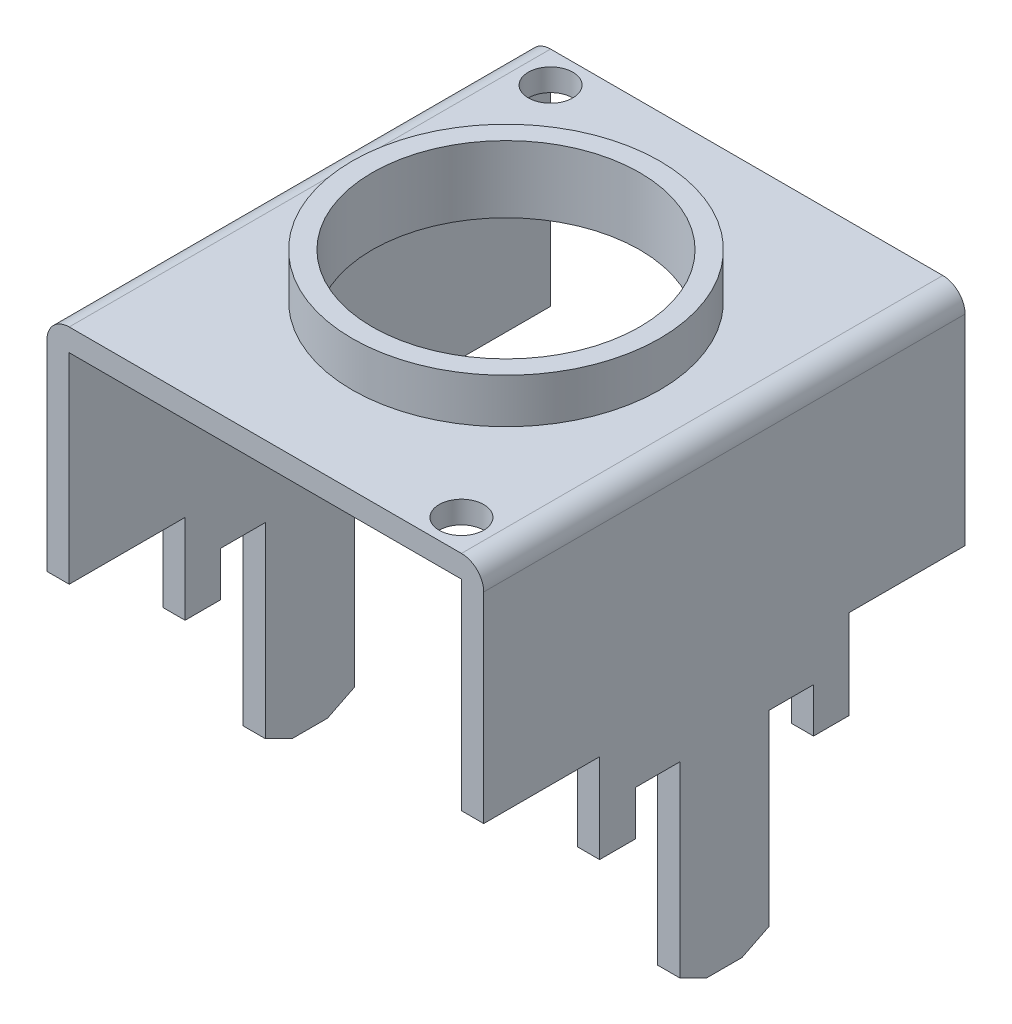
from build123d import *

# Parameters (mm, degrees)
EXTRU_MINCE1_DEPTH           = 5.4
EXTRU_MINCE1_DEPTH_BACK      = 5.4
ENL_V_MAT_EXTRU_1_DEPTH      = 5.9
ENL_V_MAT_EXTRU_1_DEPTH_BACK = 5.9
ESQUISSE4_R                  = 0.5
ENL_V_MAT_EXTRU_2_DEPTH      = 11.5
ESQUISSE5_R                  = 3.45
ESQUISSE5_R_2                = 3
BOSS_EXTRU_1_DEPTH           = 1
ESQUISSE6_R                  = 3
ENL_V_MAT_EXTRU_3_DEPTH      = 11.5


with BuildPart() as part:
    # Esquisse1 → Extru.-Mince1 (new body, two sides)
    with BuildSketch(Plane.XY) as extru_mince1_sk:
        with BuildLine():
            Line((-4.9, -3.5), (-4.9, 6.5))
            ThreePointArc((-4.9, 6.5), (-4.753553391, 6.853553391), (-4.4, 7))
            Line((-4.4, 7), (4.4, 7))
            ThreePointArc((4.4, 7), (4.753553391, 6.853553391), (4.9, 6.5))
            Line((4.9, 6.5), (4.9, -3.5))
            Line((4.9, -3.5), (4.4, -3.5))
            Line((4.4, -3.5), (4.4, 6.5))
            Line((4.4, 6.5), (-4.4, 6.5))
            Line((-4.4, 6.5), (-4.4, -3.5))
            Line((-4.4, -3.5), (-4.9, -3.5))
        make_face()
    extrude(amount=EXTRU_MINCE1_DEPTH)
    extrude(extru_mince1_sk.sketch, amount=-EXTRU_MINCE1_DEPTH_BACK)

    # Esquisse3 → Enlèv. mat.-Extru.1 (cut, two sides)
    with BuildSketch(Plane(origin=(0, 0, 0), x_dir=(0, 0, -1), z_dir=(1, 0, 0))) as enl_v_mat_extru_1_sk:
        Polygon((-6, 2), (-2.8, 2), (-2.8, 0), (-2, 0), (-2, 1), (-1, 1), (-1, 0), (-1, -3.2), (-0.395344162, -3.5), (0.395344162, -3.5), (1, -3.2), (1, 0), (1, 1), (2, 1), (2, 0), (2.8, 0), (2.8, 2), (6, 2), (6, -5), (-6, -5), align=None)
    extrude(amount=ENL_V_MAT_EXTRU_1_DEPTH, mode=Mode.SUBTRACT)
    extrude(enl_v_mat_extru_1_sk.sketch, amount=-ENL_V_MAT_EXTRU_1_DEPTH_BACK, mode=Mode.SUBTRACT)

    # Esquisse4 → Enlèv. mat.-Extru.2 (cut, through all)
    with BuildSketch(Plane(origin=(0, 7, 0), x_dir=(1, 0, 0), z_dir=(0, 1, 0))):
        with Locations(Location((-3.7, 4.7, 0), (0, 0, 180))):  # turned: the seam where the file's is
            Circle(ESQUISSE4_R)
        with Locations(Location((3.7, -4.7, 0), (0, 0, 180))):  # turned: the seam where the file's is
            Circle(ESQUISSE4_R)
    extrude(amount=-ENL_V_MAT_EXTRU_2_DEPTH, mode=Mode.SUBTRACT)

    # Esquisse5 → Boss.-Extru.1 (add)
    with BuildSketch(Plane(origin=(0, 7, 0), x_dir=(1, 0, 0), z_dir=(0, 1, 0))):
        Circle(ESQUISSE5_R)
        with Locations(Location((0, 0, 0), (0, 0, 180))):  # turned: the seam where the file's is
            Circle(ESQUISSE5_R_2, mode=Mode.SUBTRACT)
    extrude(amount=BOSS_EXTRU_1_DEPTH)

    # Esquisse6 → Enlèv. mat.-Extru.3 (cut, through all)
    with BuildSketch(Plane(origin=(0, 7, 0), x_dir=(1, 0, 0), z_dir=(0, 1, 0))):
        Circle(ESQUISSE6_R)
    extrude(amount=-ENL_V_MAT_EXTRU_3_DEPTH, mode=Mode.SUBTRACT)


solid = part.part
